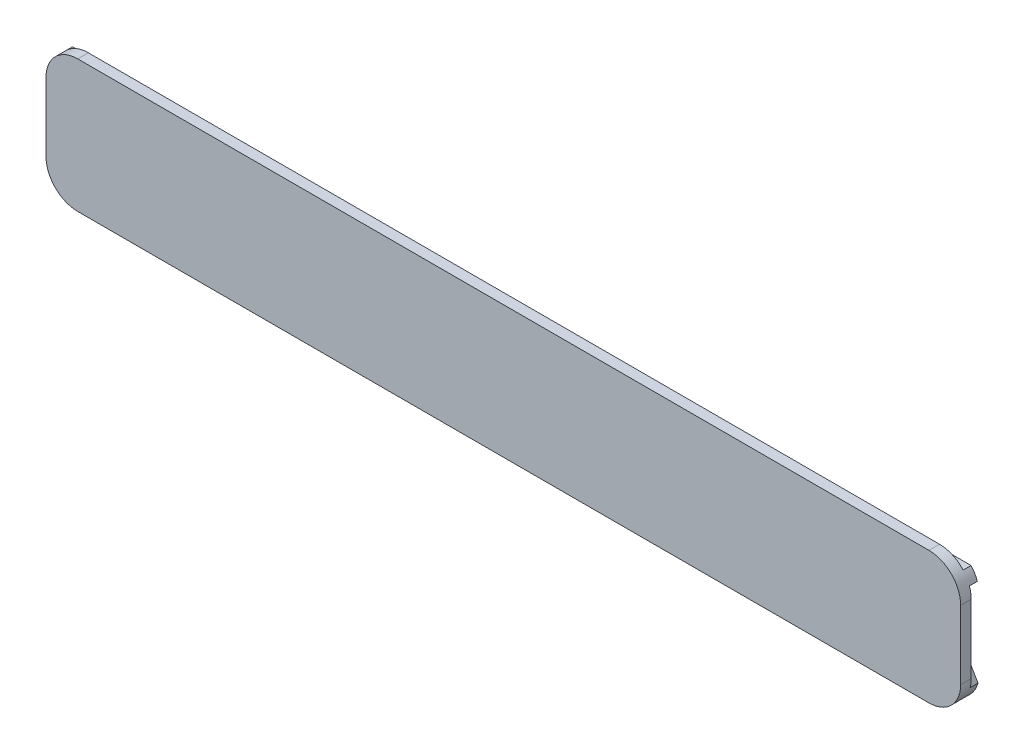
from build123d import *

# Parameters (mm, degrees)
SKETCH1_W           = 173
SKETCH1_H           = 25
SKETCH1_R           = 3.2
BOSS_EXTRUDE1_DEPTH = 1
SKETCH2_W           = 173
SKETCH2_H           = 25
BOSS_EXTRUDE2_DEPTH = 1
SKETCH6_R           = 5.2
SKETCH6_R_2         = 3.2
BOSS_EXTRUDE5_DEPTH = 2.5
BOSS_EXTRUDE4_DEPTH = 1.5
FILLET1_R           = 6


with BuildPart() as part:
    # Sketch1 → Boss-Extrude1 (new body)
    with BuildSketch(Plane.XY):
        with Locations((27.85, 0)):
            Rectangle(SKETCH1_W, SKETCH1_H)
        Circle(SKETCH1_R, mode=Mode.SUBTRACT)
        with Locations((55.7, 0)):
            Circle(SKETCH1_R, mode=Mode.SUBTRACT)
    extrude(amount=-BOSS_EXTRUDE1_DEPTH)

    # Sketch2 → Boss-Extrude2 (add)
    with BuildSketch(Plane.XY):
        with Locations((27.85, 0)):
            Rectangle(SKETCH2_W, SKETCH2_H)
    extrude(amount=BOSS_EXTRUDE2_DEPTH)

    # Sketch6 → Boss-Extrude5 (add)
    with BuildSketch(Plane(origin=(0, 0, -1), x_dir=(-1, 0, 0), z_dir=(0, 0, -1))):
        with Locations(Location((-55.7, 0, 0), (0, 0, 180))):
            Circle(SKETCH6_R)
        with Locations(Location((-55.7, 0, 0), (0, 0, 180))):
            Circle(SKETCH6_R_2, mode=Mode.SUBTRACT)
        with Locations(Location((0, 0, 0), (0, 0, 180))):
            Circle(SKETCH6_R)
        with Locations(Location((0, 0, 0), (0, 0, 180))):
            Circle(SKETCH6_R_2, mode=Mode.SUBTRACT)
    extrude(amount=BOSS_EXTRUDE5_DEPTH)

    # Sketch5 → Boss-Extrude4 (add)
    with BuildSketch(Plane(origin=(0, 0, -1), x_dir=(-1, 0, 0), z_dir=(0, 0, -1))):
        Polygon((-27.85, -10.5), (-27.85, -8.5), (-28.85, -8.5), (-38.664954576, 8.5), (-27.85, 8.5), (-27.85, 10.5), (-114.35, 10.5), (-114.35, 8.5), (-104.535045424, 8.5), (-114.35, -8.5), (-114.35, -10.5), align=None)
        Polygon((-112.040598923, -8.5), (-90.410689771, -8.5), (-100.225644347, 8.5), (-102.225644347, 8.5), align=None, mode=Mode.SUBTRACT)
        Polygon((-97.91624327, 8.5), (-88.101288694, -8.5), (-86.101288694, -8.5), (-76.286334118, 8.5), align=None, mode=Mode.SUBTRACT)
        Polygon((-83.791887617, -8.5), (-73.976933041, 8.5), (-45.044908014, 8.5), (-49.600044285, -8.5), align=None, mode=Mode.SUBTRACT)
        Polygon((-40.974355653, 8.5), (-31.159401077, -8.5), (-47.529491924, -8.5), (-42.974355653, 8.5), align=None, mode=Mode.SUBTRACT)
    boss_extrude4 = extrude(amount=BOSS_EXTRUDE4_DEPTH)

    # Mirror1: Boss-Extrude4 across plane
    add(boss_extrude4.mirror(Plane(origin=(27.85, 0, 0), x_dir=(0, 0, 1), z_dir=(1, 0, 0))))

    # Fillet1
    fillet1_edges = [part.edges().sort_by_distance(p)[0] for p in [
        (114.35, 12.5, 0),
        (114.35, -12.5, 0),
        (-58.65, -12.5, 0),
        (-58.65, 12.5, 0),
    ]]
    fillet(fillet1_edges, radius=FILLET1_R)


solid = part.part
